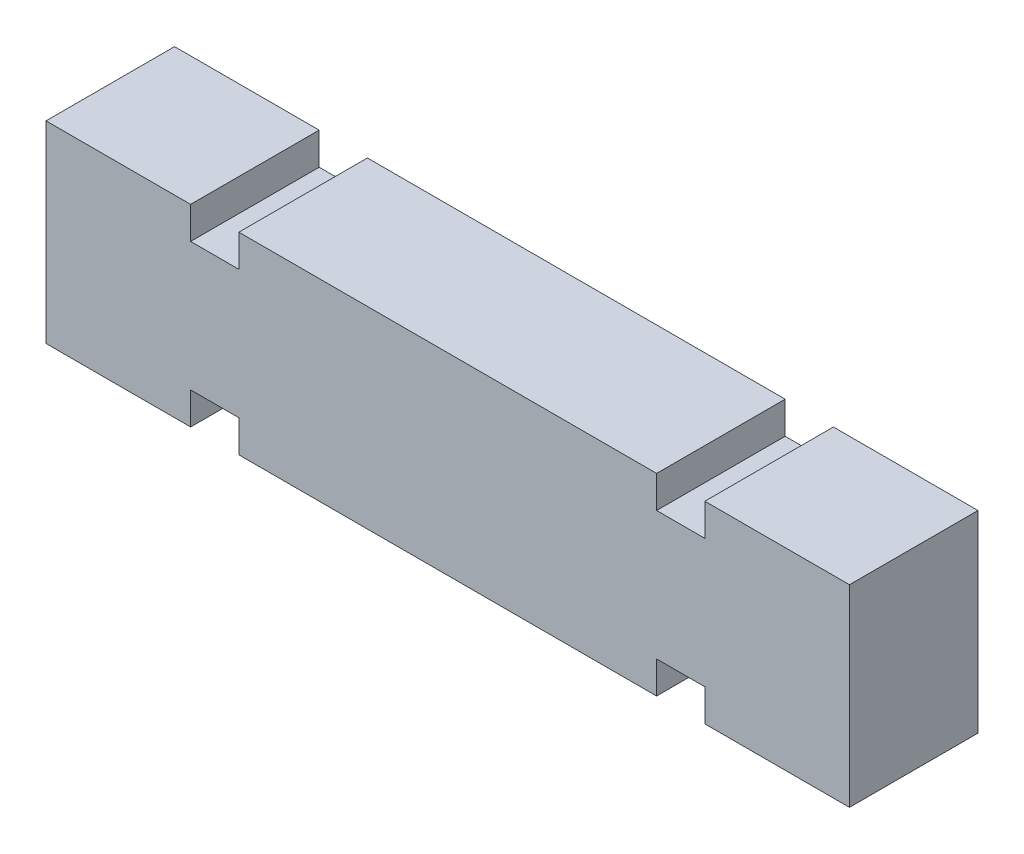
from build123d import *

# Parameters (mm, degrees)
SKETCH_1_W          = 4
SKETCH_1_H          = 6
EXTRUDE_1_DEPTH     = 25
SKETCH_3_W          = 1.5
SKETCH_3_H          = 1
CUT_EXTRUDE_1_DEPTH = 10


with BuildPart() as part:
    # 草图1 → 凸台-拉伸1 (new body)
    with BuildSketch(Plane(origin=(0, 0, 0), x_dir=(0, 0, -1), z_dir=(1, 0, 0))):
        with Locations((0, 3)):
            Rectangle(SKETCH_1_W, SKETCH_1_H)
    extrude(amount=EXTRUDE_1_DEPTH)

    # 草图3 → 切除-拉伸1 (cut, symmetric)
    with BuildSketch(Plane.XY):
        with Locations((5.25, 0.5)):
            Rectangle(SKETCH_3_W, SKETCH_3_H)
        with Locations((5.25, 5.5)):
            Rectangle(SKETCH_3_W, SKETCH_3_H)
        with Locations((19.75, 5.5)):
            Rectangle(SKETCH_3_W, SKETCH_3_H)
        with Locations((19.75, 0.5)):
            Rectangle(SKETCH_3_W, SKETCH_3_H)
    extrude(amount=CUT_EXTRUDE_1_DEPTH, both=True, mode=Mode.SUBTRACT)


solid = part.part
